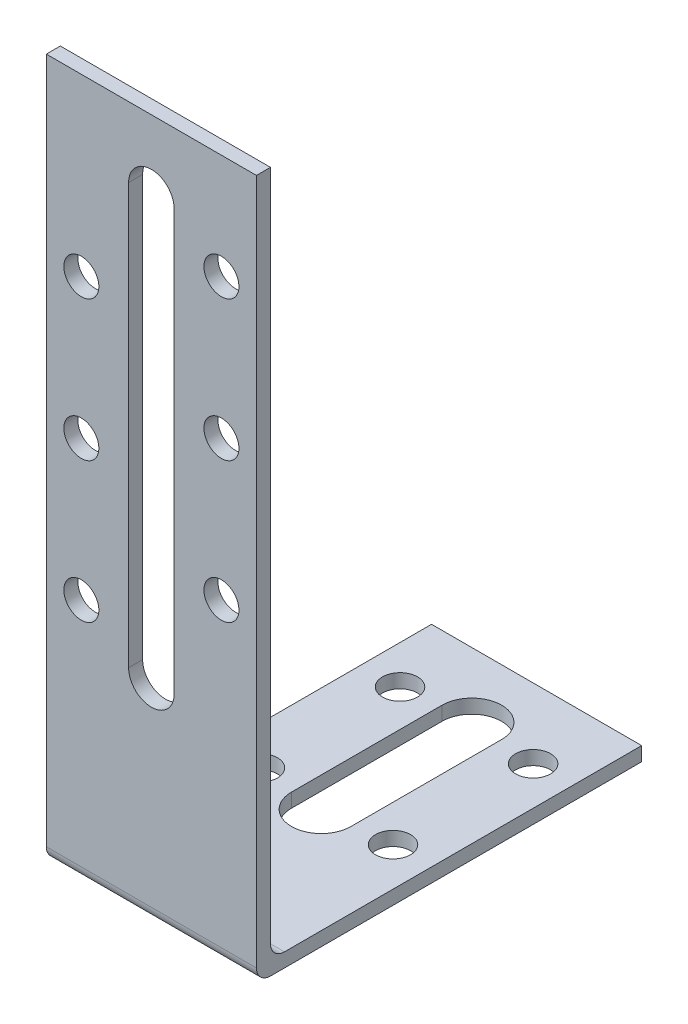
from build123d import *

# Parameters (mm, degrees)
BOSS_EXTRU_1_DEPTH      = 15
CONG_1_R                = 2
ENL_V_MAT_EXTRU_1_REACH = 4
ESQUISSE2_R             = 2.5
ENL_V_MAT_EXTRU_2_REACH = 4
ESQUISSE4_R             = 2.5


with BuildPart() as part:
    # Esquisse1 → Boss.-Extru.1 (new body, symmetric)
    with BuildSketch(Plane(origin=(0, 0, 0), x_dir=(0, 0, -1), z_dir=(1, 0, 0))):
        Polygon((0, 0), (0, 100), (2, 100), (2, 2), (55, 2), (55, 0), align=None)
    extrude(amount=BOSS_EXTRU_1_DEPTH, both=True)

    # Congé1
    cong_1_edges = [part.edges().sort_by_distance(p)[0] for p in [
        (0, 0, 0),
        (0, 2, -2),
    ]]
    fillet(cong_1_edges, radius=CONG_1_R)

    # Esquisse2 → Enlèv. mat.-Extru.1 (cut, up to next)
    with BuildSketch(Plane(origin=(0, 2, 0), x_dir=(1, 0, 0), z_dir=(0, 1, 0)), mode=Mode.PRIVATE) as enl_v_mat_extru_1_sk1:
        with BuildLine():
            Line((4.25, 24.25), (4.25, 45.75))
            ThreePointArc((4.25, 45.75), (0, 50), (-4.25, 45.75))
            Line((-4.25, 45.75), (-4.25, 24.25))
            ThreePointArc((-4.25, 24.25), (0, 20), (4.25, 24.25))
        make_face()
    enl_v_mat_extru_1_tool1 = extrude(enl_v_mat_extru_1_sk1.sketch, amount=-ENL_V_MAT_EXTRU_1_REACH, mode=Mode.PRIVATE) & part.part
    add(enl_v_mat_extru_1_tool1.solids().sort_by_distance((0, 2, -35))[0], mode=Mode.SUBTRACT)
    # Esquisse2 → Enlèv. mat.-Extru.1 (cut, up to next)
    with BuildSketch(Plane(origin=(0, 2, 0), x_dir=(1, 0, 0), z_dir=(0, 1, 0)), mode=Mode.PRIVATE) as enl_v_mat_extru_1_sk2:
        with Locations((-9.5, 25)):
            Circle(ESQUISSE2_R)
    enl_v_mat_extru_1_tool2 = extrude(enl_v_mat_extru_1_sk2.sketch, amount=-ENL_V_MAT_EXTRU_1_REACH, mode=Mode.PRIVATE) & part.part
    add(enl_v_mat_extru_1_tool2.solids().sort_by_distance((-9.5, 2, -25))[0], mode=Mode.SUBTRACT)
    # Esquisse2 → Enlèv. mat.-Extru.1 (cut, up to next)
    with BuildSketch(Plane(origin=(0, 2, 0), x_dir=(1, 0, 0), z_dir=(0, 1, 0)), mode=Mode.PRIVATE) as enl_v_mat_extru_1_sk3:
        with Locations((-9.5, 45)):
            Circle(ESQUISSE2_R)
    enl_v_mat_extru_1_tool3 = extrude(enl_v_mat_extru_1_sk3.sketch, amount=-ENL_V_MAT_EXTRU_1_REACH, mode=Mode.PRIVATE) & part.part
    add(enl_v_mat_extru_1_tool3.solids().sort_by_distance((-9.5, 2, -45))[0], mode=Mode.SUBTRACT)
    # Esquisse2 → Enlèv. mat.-Extru.1 (cut, up to next)
    with BuildSketch(Plane(origin=(0, 2, 0), x_dir=(1, 0, 0), z_dir=(0, 1, 0)), mode=Mode.PRIVATE) as enl_v_mat_extru_1_sk4:
        with Locations((9.5, 45)):
            Circle(ESQUISSE2_R)
    enl_v_mat_extru_1_tool4 = extrude(enl_v_mat_extru_1_sk4.sketch, amount=-ENL_V_MAT_EXTRU_1_REACH, mode=Mode.PRIVATE) & part.part
    add(enl_v_mat_extru_1_tool4.solids().sort_by_distance((9.5, 2, -45))[0], mode=Mode.SUBTRACT)
    # Esquisse2 → Enlèv. mat.-Extru.1 (cut, up to next)
    with BuildSketch(Plane(origin=(0, 2, 0), x_dir=(1, 0, 0), z_dir=(0, 1, 0)), mode=Mode.PRIVATE) as enl_v_mat_extru_1_sk5:
        with Locations((9.5, 25)):
            Circle(ESQUISSE2_R)
    enl_v_mat_extru_1_tool5 = extrude(enl_v_mat_extru_1_sk5.sketch, amount=-ENL_V_MAT_EXTRU_1_REACH, mode=Mode.PRIVATE) & part.part
    add(enl_v_mat_extru_1_tool5.solids().sort_by_distance((9.5, 2, -25))[0], mode=Mode.SUBTRACT)

    # Esquisse4 → Enlèv. mat.-Extru.2 (cut, up to next)
    with BuildSketch(Plane(origin=(0, 0, -2), x_dir=(-1, 0, 0), z_dir=(0, 0, -1)), mode=Mode.PRIVATE) as enl_v_mat_extru_2_sk1:
        with Locations((-10, 85)):
            Circle(ESQUISSE4_R)
    enl_v_mat_extru_2_tool1 = extrude(enl_v_mat_extru_2_sk1.sketch, amount=-ENL_V_MAT_EXTRU_2_REACH, mode=Mode.PRIVATE) & part.part
    add(enl_v_mat_extru_2_tool1.solids().sort_by_distance((10, 85, -2))[0], mode=Mode.SUBTRACT)
    # Esquisse4 → Enlèv. mat.-Extru.2 (cut, up to next)
    with BuildSketch(Plane(origin=(0, 0, -2), x_dir=(-1, 0, 0), z_dir=(0, 0, -1)), mode=Mode.PRIVATE) as enl_v_mat_extru_2_sk2:
        with Locations((-10, 65)):
            Circle(ESQUISSE4_R)
    enl_v_mat_extru_2_tool2 = extrude(enl_v_mat_extru_2_sk2.sketch, amount=-ENL_V_MAT_EXTRU_2_REACH, mode=Mode.PRIVATE) & part.part
    add(enl_v_mat_extru_2_tool2.solids().sort_by_distance((10, 65, -2))[0], mode=Mode.SUBTRACT)
    # Esquisse4 → Enlèv. mat.-Extru.2 (cut, up to next)
    with BuildSketch(Plane(origin=(0, 0, -2), x_dir=(-1, 0, 0), z_dir=(0, 0, -1)), mode=Mode.PRIVATE) as enl_v_mat_extru_2_sk3:
        with Locations((-10, 45)):
            Circle(ESQUISSE4_R)
    enl_v_mat_extru_2_tool3 = extrude(enl_v_mat_extru_2_sk3.sketch, amount=-ENL_V_MAT_EXTRU_2_REACH, mode=Mode.PRIVATE) & part.part
    add(enl_v_mat_extru_2_tool3.solids().sort_by_distance((10, 45, -2))[0], mode=Mode.SUBTRACT)
    # Esquisse4 → Enlèv. mat.-Extru.2 (cut, up to next)
    with BuildSketch(Plane(origin=(0, 0, -2), x_dir=(-1, 0, 0), z_dir=(0, 0, -1)), mode=Mode.PRIVATE) as enl_v_mat_extru_2_sk4:
        with Locations((10, 75)):
            Circle(ESQUISSE4_R)
    enl_v_mat_extru_2_tool4 = extrude(enl_v_mat_extru_2_sk4.sketch, amount=-ENL_V_MAT_EXTRU_2_REACH, mode=Mode.PRIVATE) & part.part
    add(enl_v_mat_extru_2_tool4.solids().sort_by_distance((-10, 75, -2))[0], mode=Mode.SUBTRACT)
    # Esquisse4 → Enlèv. mat.-Extru.2 (cut, up to next)
    with BuildSketch(Plane(origin=(0, 0, -2), x_dir=(-1, 0, 0), z_dir=(0, 0, -1)), mode=Mode.PRIVATE) as enl_v_mat_extru_2_sk5:
        with Locations((10, 55)):
            Circle(ESQUISSE4_R)
    enl_v_mat_extru_2_tool5 = extrude(enl_v_mat_extru_2_sk5.sketch, amount=-ENL_V_MAT_EXTRU_2_REACH, mode=Mode.PRIVATE) & part.part
    add(enl_v_mat_extru_2_tool5.solids().sort_by_distance((-10, 55, -2))[0], mode=Mode.SUBTRACT)
    # Esquisse4 → Enlèv. mat.-Extru.2 (cut, up to next)
    with BuildSketch(Plane(origin=(0, 0, -2), x_dir=(-1, 0, 0), z_dir=(0, 0, -1)), mode=Mode.PRIVATE) as enl_v_mat_extru_2_sk6:
        with Locations((10, 35)):
            Circle(ESQUISSE4_R)
    enl_v_mat_extru_2_tool6 = extrude(enl_v_mat_extru_2_sk6.sketch, amount=-ENL_V_MAT_EXTRU_2_REACH, mode=Mode.PRIVATE) & part.part
    add(enl_v_mat_extru_2_tool6.solids().sort_by_distance((-10, 35, -2))[0], mode=Mode.SUBTRACT)
    # Esquisse4 → Enlèv. mat.-Extru.2 (cut, up to next)
    with BuildSketch(Plane(origin=(0, 0, -2), x_dir=(-1, 0, 0), z_dir=(0, 0, -1)), mode=Mode.PRIVATE) as enl_v_mat_extru_2_sk7:
        with BuildLine():
            Line((3.25, 90), (3.25, 30))
            ThreePointArc((3.25, 30), (0, 26.75), (-3.25, 30))
            Line((-3.25, 30), (-3.25, 90))
            ThreePointArc((-3.25, 90), (0, 93.25), (3.25, 90))
        make_face()
    enl_v_mat_extru_2_tool7 = extrude(enl_v_mat_extru_2_sk7.sketch, amount=-ENL_V_MAT_EXTRU_2_REACH, mode=Mode.PRIVATE) & part.part
    add(enl_v_mat_extru_2_tool7.solids().sort_by_distance((0, 60, -2))[0], mode=Mode.SUBTRACT)


solid = part.part
